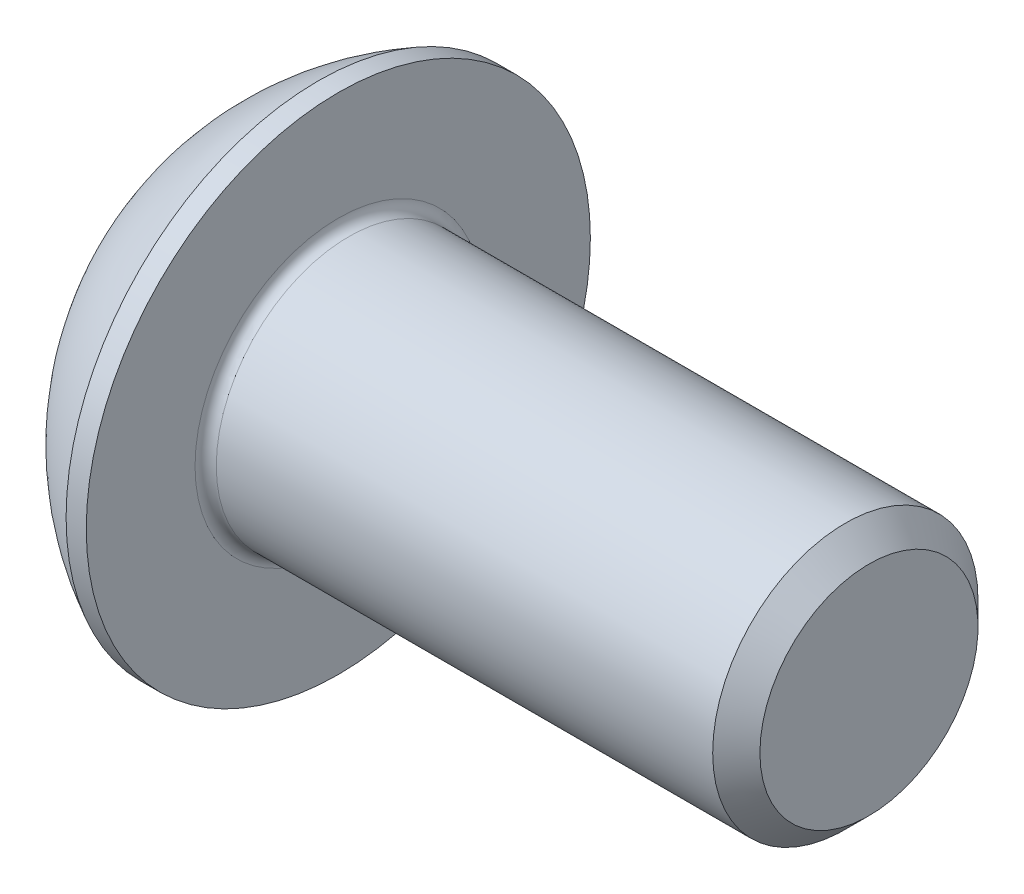
from build123d import *

# Parameters (mm, degrees)
FILLET1_R   = 0.2
HEX_2_DEPTH = 1.56


with BuildPart() as part:
    # BodySke → BaseBody (revolve)
    with BuildSketch(Plane.XY, mode=Mode.PRIVATE) as basebody_sk:
        with BuildLine():
            Line((12.75, 0), (12.75, 2.055))
            Line((12.75, 2.055), (12.305, 2.5))
            Line((12.305, 2.5), (2.75, 2.5))
            Line((2.75, 2.5), (2.75, 4.75))
            Line((2.75, 4.75), (2.37, 4.75))
            ThreePointArc((2.37, 4.75), (0.992680215, 3.754414901), (0, 2.375))
            Line((0, 2.375), (0, 0))
            Line((0, 0), (12.75, 0))
        make_face()
    revolve(basebody_sk.sketch.rotate(Axis((0, 0, 0), (1, 0, 0)), 90), axis=Axis((0, 0, 0), (1, 0, 0)))  # turned: the seam where the file's is

    # Fillet1
    fillet1_edges = [part.edges().sort_by_distance(p)[0] for p in [
        (2.75, 0, -2.5),
    ]]
    fillet(fillet1_edges, radius=FILLET1_R)

    # Sketch2 → PreBroach (revolve, cut)
    with BuildSketch(Plane.XY, mode=Mode.PRIVATE) as prebroach_sk:
        Polygon((0, 1.5), (1.56, 1.5), (2.426025404, 0), (0, 0), align=None)
    revolve(prebroach_sk.sketch.rotate(Axis((0, 0, 0), (1, 0, 0)), 90), axis=Axis((0, 0, 0), (1, 0, 0)), mode=Mode.SUBTRACT)  # turned: the seam where the file's is

    # Sketch3 → Hex 2 (cut)
    with BuildSketch(Plane(origin=(0, 0, 0), x_dir=(0, 0, -1), z_dir=(1, 0, 0))):
        Polygon((-1.5, -0.866025404), (-1.5, 0.866025404), (0, 1.732050808), (1.5, 0.866025404), (1.5, -0.866025404), (0, -1.732050808), align=None)
    extrude(amount=HEX_2_DEPTH, mode=Mode.SUBTRACT)


solid = part.part
